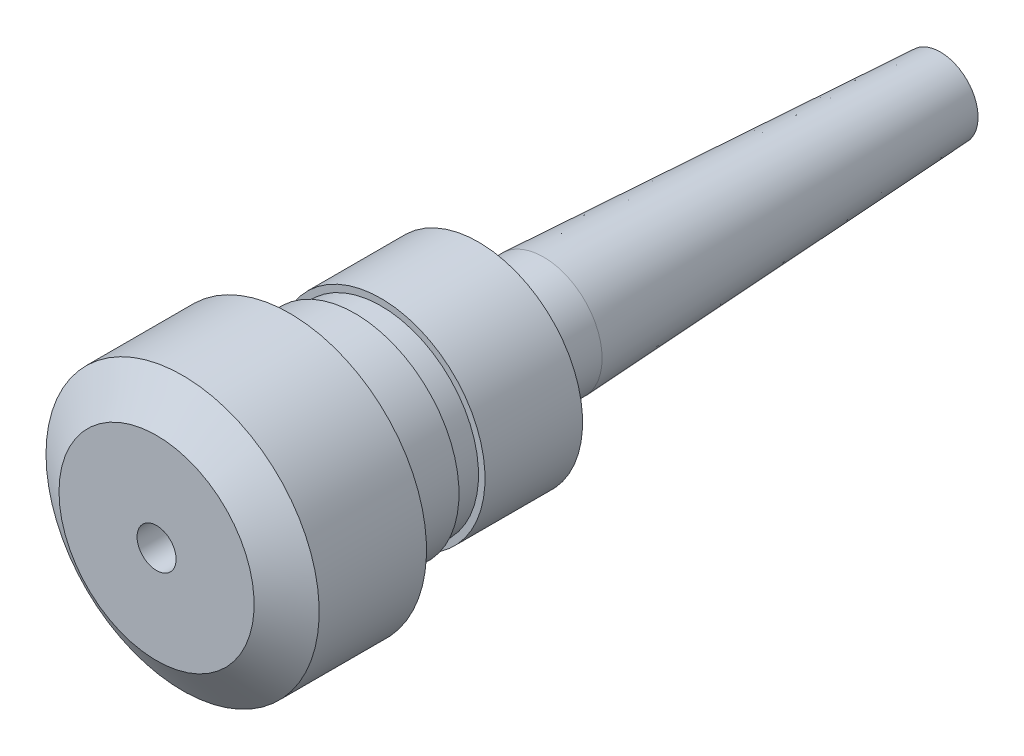
from build123d import *

# Parameters (mm, degrees)
SKETCH2_R           = 9
BOSS_EXTRUDE1_DEPTH = 10
SKETCH3_R           = 9
BOSS_EXTRUDE2_DEPTH = 61
BOSS_EXTRUDE2_TAPER = 3
SKETCH4_R           = 4
CUT_EXTRUDE1_DEPTH  = 61


with BuildPart() as part:
    # Sketch1 → Revolve1 (revolve)
    with BuildSketch(Plane(origin=(0, 0, 0), x_dir=(1, 0, 0), z_dir=(0, 1, 0))):
        Polygon((3, 0), (15, 0), (21, 4), (21, 20.5), (16, 20.5), (16, 30.5), (15, 30.5), (15, 34.5), (16, 34.5), (16, 49.5), (0, 49.5), (0, 30), (3, 30), align=None)
    revolve(axis=Axis((0, 0, -75.9090067), (0, 0, 1)))

    # Sketch2 → Boss-Extrude1 (add)
    with BuildSketch(Plane(origin=(0, 0, -49.5), x_dir=(-1, 0, 0), z_dir=(0, 0, -1))):
        Circle(SKETCH2_R)
    extrude(amount=BOSS_EXTRUDE1_DEPTH)

    # Sketch3 → Boss-Extrude2 (add)
    with BuildSketch(Plane(origin=(0, 0, -59.5), x_dir=(-1, 0, 0), z_dir=(0, 0, -1))):
        Circle(SKETCH3_R)
    extrude(amount=BOSS_EXTRUDE2_DEPTH, taper=BOSS_EXTRUDE2_TAPER)

    # Sketch4 → Cut-Extrude1 (cut)
    with BuildSketch(Plane(origin=(0, 0, -120.5), x_dir=(-1, 0, 0), z_dir=(0, 0, -1))):
        Circle(SKETCH4_R)
    extrude(amount=-CUT_EXTRUDE1_DEPTH, mode=Mode.SUBTRACT)


solid = part.part
